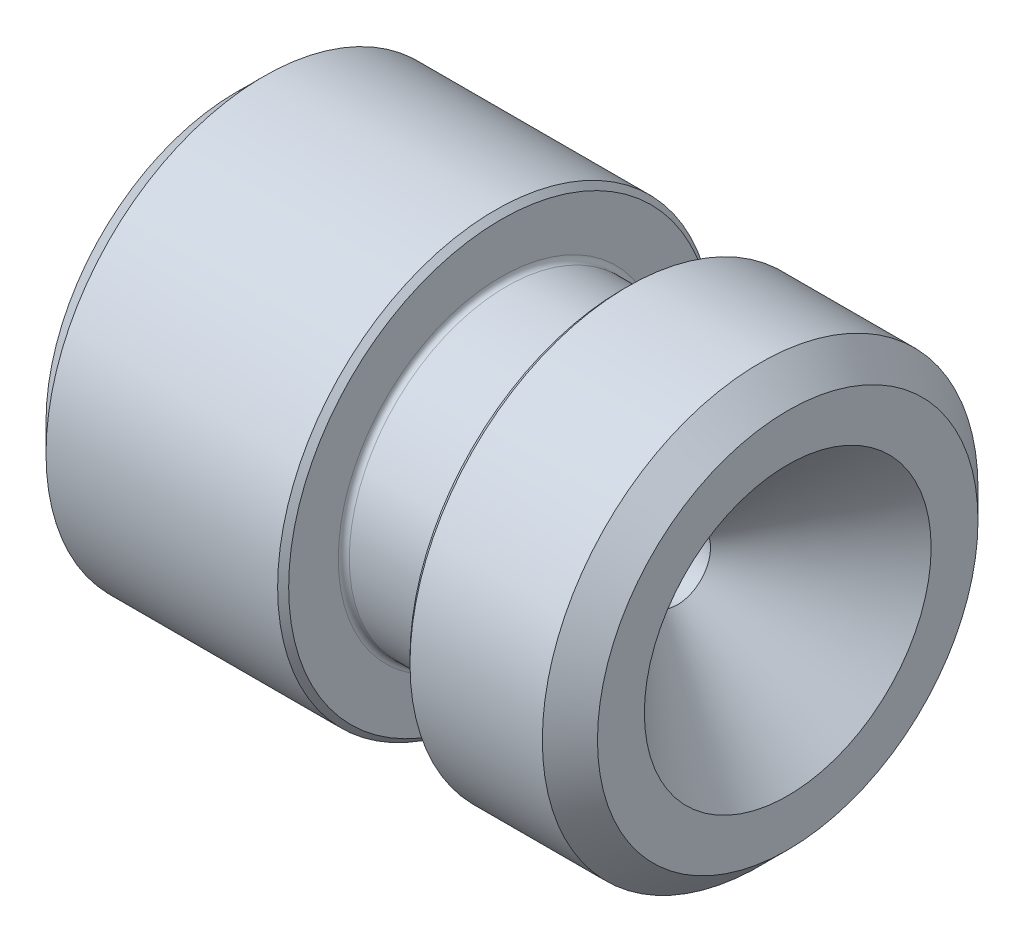
from build123d import *

# Parameters (mm, degrees)
CHAMFER1_SIZE = 0.5
FILLET1_R     = 0.1
CHAMFER2_SIZE = 0.1


with BuildPart() as part:
    # Sketch1 → Revolve1 (revolve)
    with BuildSketch(Plane.XY):
        Polygon((-8, -2.743593539), (-8, -3.95), (-3.2, -3.95), (-3.2, -2.85), (-1, -2.85), (-1, -3.95), (2, -3.95), (2, -2.6), (0, -0.6), align=None)
    revolve(axis=Axis((-24.298547045, 0, 0), (1, 0, 0)))

    # Chamfer1
    chamfer1_edges = [part.edges().sort_by_distance(p)[0] for p in [
        (-8, 3.95, 0),
        (2, 3.95, 0),
    ]]
    chamfer(chamfer1_edges, length=CHAMFER1_SIZE)

    # Fillet1
    fillet1_edges = [part.edges().sort_by_distance(p)[0] for p in [
        (-1, 2.85, 0),
        (-3.2, 2.85, 0),
    ]]
    fillet(fillet1_edges, radius=FILLET1_R)

    # Chamfer2
    chamfer2_edges = [part.edges().sort_by_distance(p)[0] for p in [
        (-3.2, 3.95, 0),
        (-1, 3.95, 0),
    ]]
    chamfer(chamfer2_edges, length=CHAMFER2_SIZE)


solid = part.part
